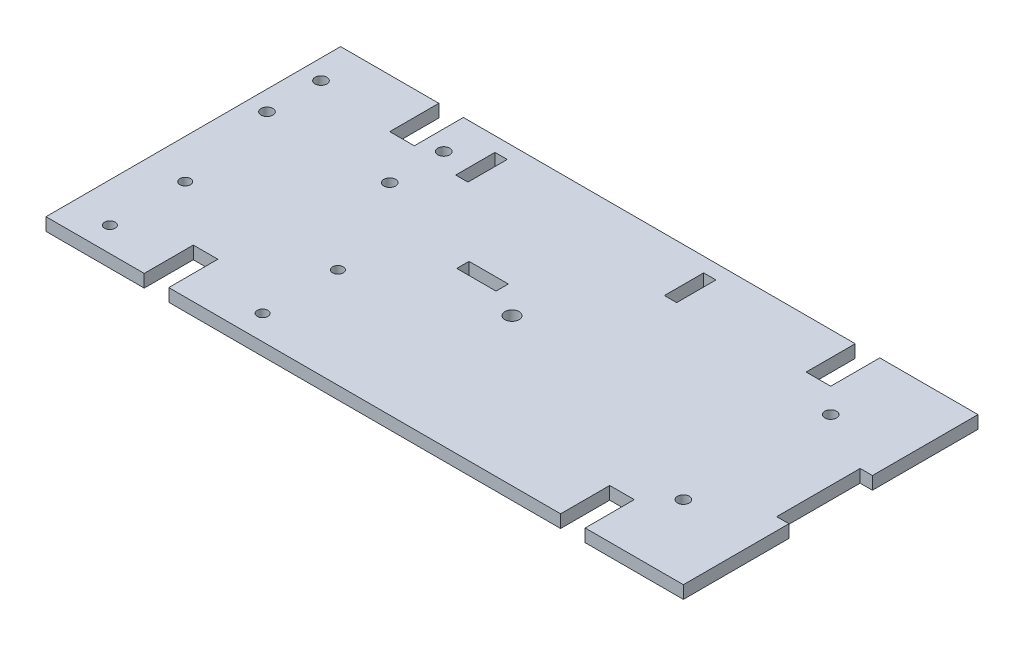
from build123d import *

# Parameters (mm, degrees)
SKETCH1_R           = 1.8288
BOSS_EXTRUDE1_DEPTH = 3.302
SKETCH2_R           = 1.524
CUT_EXTRUDE1_DEPTH  = 4.302
SKETCH3_R           = 1.375
CUT_EXTRUDE2_DEPTH  = 4.302
SKETCH4_W           = 3.175
SKETCH4_H           = 10.16
SKETCH4_W_2         = 10.16
SKETCH4_H_2         = 3.175
CUT_EXTRUDE3_DEPTH  = 4.302
SKETCH5_R           = 1.524
CUT_EXTRUDE4_DEPTH  = 4.302


with BuildPart() as part:
    # Sketch1 → Boss-Extrude1 (new body)
    with BuildSketch(Plane(origin=(0, 0, 0), x_dir=(1, 0, 0), z_dir=(0, 1, 0))):
        Polygon((-164.846, 76.2), (-139.446, 76.2), (-139.446, 63.5), (-133.096, 63.5), (-133.096, 76.2), (-31.75, 76.2), (-31.75, 63.5), (-25.4, 63.5), (-25.4, 76.2), (0, 76.2), (0, 48.895), (-3.175, 48.895), (-3.175, 27.305), (0, 27.305), (0, 0), (-25.4, 0), (-25.4, 12.7), (-31.75, 12.7), (-31.75, 0), (-133.096, 0), (-133.096, 12.7), (-139.446, 12.7), (-139.446, 0), (-164.846, 0), (-164.846, 27.305), (-164.846, 48.895), align=None)
        with Locations((-82.423, 38.1)):
            Circle(SKETCH1_R, mode=Mode.SUBTRACT)
    extrude(amount=BOSS_EXTRUDE1_DEPTH)

    # Sketch2 → Cut-Extrude1 (cut, through all)
    with BuildSketch(Plane(origin=(0, 3.302, 0), x_dir=(1, 0, 0), z_dir=(0, 1, 0))):
        with Locations((-159.766, 66.04)):
            Circle(SKETCH2_R)
        with Locations((-128.016, 66.04)):
            Circle(SKETCH2_R)
        with Locations((-128.016, 52.07)):
            Circle(SKETCH2_R)
        with Locations((-159.766, 52.07)):
            Circle(SKETCH2_R)
    extrude(amount=-CUT_EXTRUDE1_DEPTH, mode=Mode.SUBTRACT)

    # Sketch3 → Cut-Extrude2 (cut, through all)
    with BuildSketch(Plane(origin=(0, 3.302, 0), x_dir=(1, 0, 0), z_dir=(0, 1, 0))):
        with Locations((-154.686, 6.35)):
            Circle(SKETCH3_R)
        with Locations((-115.186, 6.35)):
            Circle(SKETCH3_R)
        with Locations((-115.186, 25.85)):
            Circle(SKETCH3_R)
        with Locations((-154.686, 25.85)):
            Circle(SKETCH3_R)
    extrude(amount=-CUT_EXTRUDE2_DEPTH, mode=Mode.SUBTRACT)

    # Sketch4 → Cut-Extrude3 (cut, through all)
    with BuildSketch(Plane(origin=(0, 3.302, 0), x_dir=(1, 0, 0), z_dir=(0, 1, 0))):
        with Locations((-65.63129104, 67.386847386)):
            Rectangle(SKETCH4_W, SKETCH4_H)
        with Locations((-95.06194853, 43.1165)):
            Rectangle(SKETCH4_W_2, SKETCH4_H_2)
        with Locations((-119.60629104, 67.386847386)):
            Rectangle(SKETCH4_W, SKETCH4_H)
    extrude(amount=-CUT_EXTRUDE3_DEPTH, mode=Mode.SUBTRACT)

    # Sketch5 → Cut-Extrude4 (cut, through all)
    with BuildSketch(Plane(origin=(0, 3.302, 0), x_dir=(1, 0, 0), z_dir=(0, 1, 0))):
        with Locations((-19.05, 19.05)):
            Circle(SKETCH5_R)
        with Locations((-19.05, 57.15)):
            Circle(SKETCH5_R)
    extrude(amount=-CUT_EXTRUDE4_DEPTH, mode=Mode.SUBTRACT)


solid = part.part
